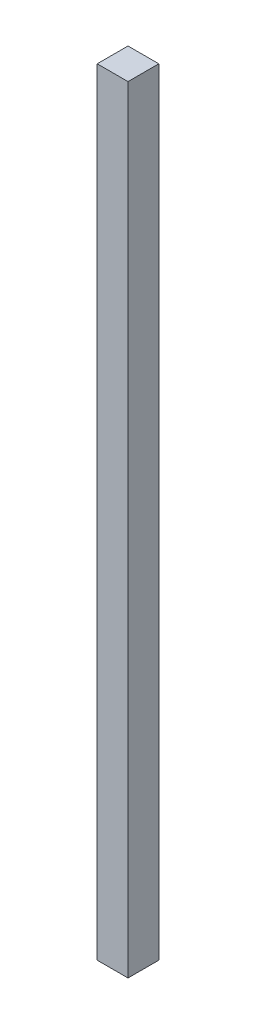
from build123d import *

# Parameters (mm, degrees)
SKETCH_1_W      = 5
SKETCH_1_H      = 5
EXTRUDE_1_DEPTH = 126


with BuildPart() as part:
    # Эскиз1 → Бобышка-Вытянуть1 (new body)
    with BuildSketch(Plane(origin=(0, 0, 0), x_dir=(1, 0, 0), z_dir=(0, 1, 0))):
        Rectangle(SKETCH_1_W, SKETCH_1_H)
    extrude(amount=EXTRUDE_1_DEPTH)


solid = part.part
